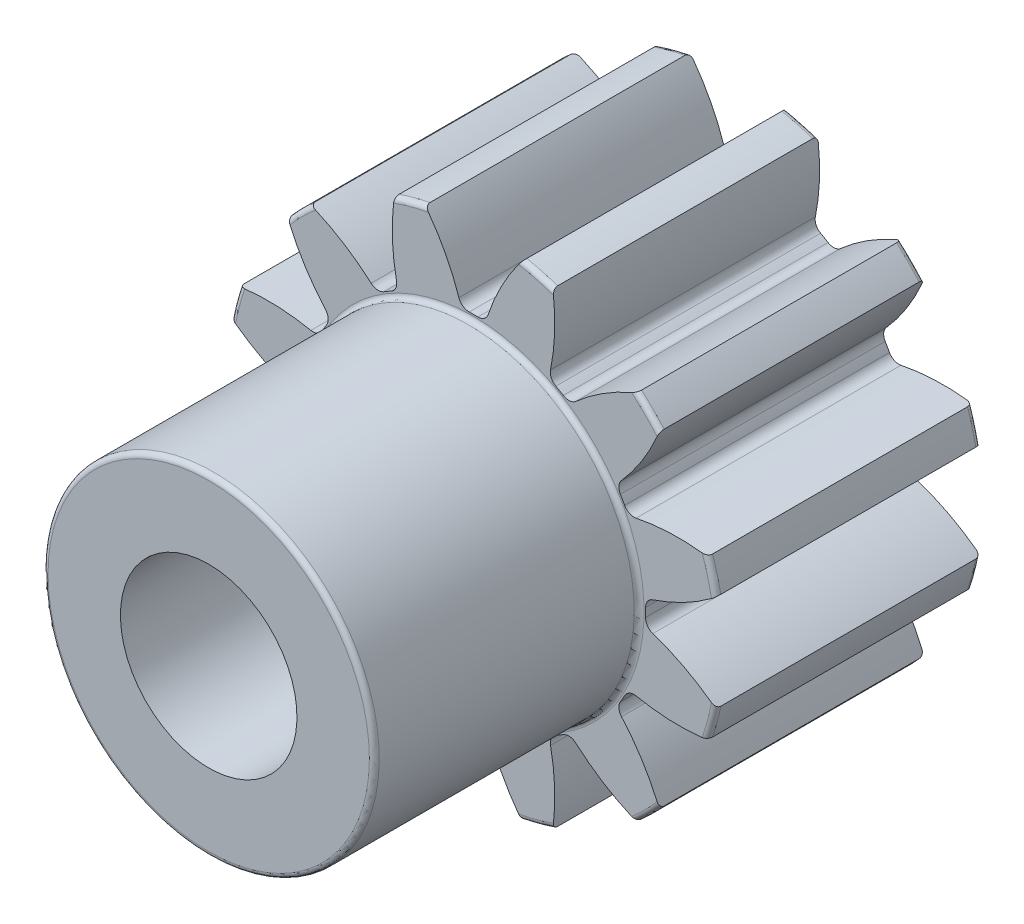
from build123d import *

# Parameters (mm, degrees)
FILLET2_R          = 0.1778
CUT_EXTRUDE2_DEPTH = 10.525
CIRPATTERN1_COUNT  = 12


with BuildPart() as part:
    # Sketch4 → Revolve1 (revolve)
    with BuildSketch(Plane(origin=(0, 0, 0), x_dir=(0, 0, -1), z_dir=(1, 0, 0))):
        Polygon((-19.05, 3.175), (-19.05, 5.9563), (-9.525, 5.9563), (-9.525, 8.89), (0, 8.89), (0, 3.175), align=None)
    revolve(axis=Axis((0, 0, 9.525), (0, 0, 1)))

    # Fillet2
    fillet2_edges = [part.edges().sort_by_distance(p)[0] for p in [
        (0, -8.89, 0),
        (0, -8.89, 9.525),
        (0, -5.9563, 9.525),
        (0, -5.9563, 19.05),
    ]]
    fillet(fillet2_edges, radius=FILLET2_R)

    # Sketch7 → Cut-Extrude2 (cut, through all)
    with BuildSketch(Plane.XY.offset(9.525)):
        with BuildLine():
            ThreePointArc((-0.154919332, 6.189311477), (0, 6.19125), (0.154919332, 6.189311477))
            ThreePointArc((0.154919332, 6.189311477), (0.38328155, 6.258296152), (0.525868022, 6.449548043))
            ThreePointArc((0.525868022, 6.449548043), (1.037149268, 7.63535058), (1.7413194, 8.717792539))
            ThreePointArc((1.7413194, 8.717792539), (0, 8.89), (-1.7413194, 8.717792539))
            ThreePointArc((-1.7413194, 8.717792539), (-1.037149268, 7.63535058), (-0.525868022, 6.449548043))
            ThreePointArc((-0.525868022, 6.449548043), (-0.38328155, 6.258296152), (-0.154919332, 6.189311477))
        make_face()
    cut_extrude2 = extrude(amount=-CUT_EXTRUDE2_DEPTH, mode=Mode.SUBTRACT)

    # CirPattern1: Cut-Extrude2 ×12 about axis
    cirpattern1_axis = Axis((0, 0, 0), (0, 0, 1))
    for i in range(1, CIRPATTERN1_COUNT):
        add(cut_extrude2.rotate(cirpattern1_axis, i * 360 / CIRPATTERN1_COUNT), mode=Mode.SUBTRACT)


solid = part.part
